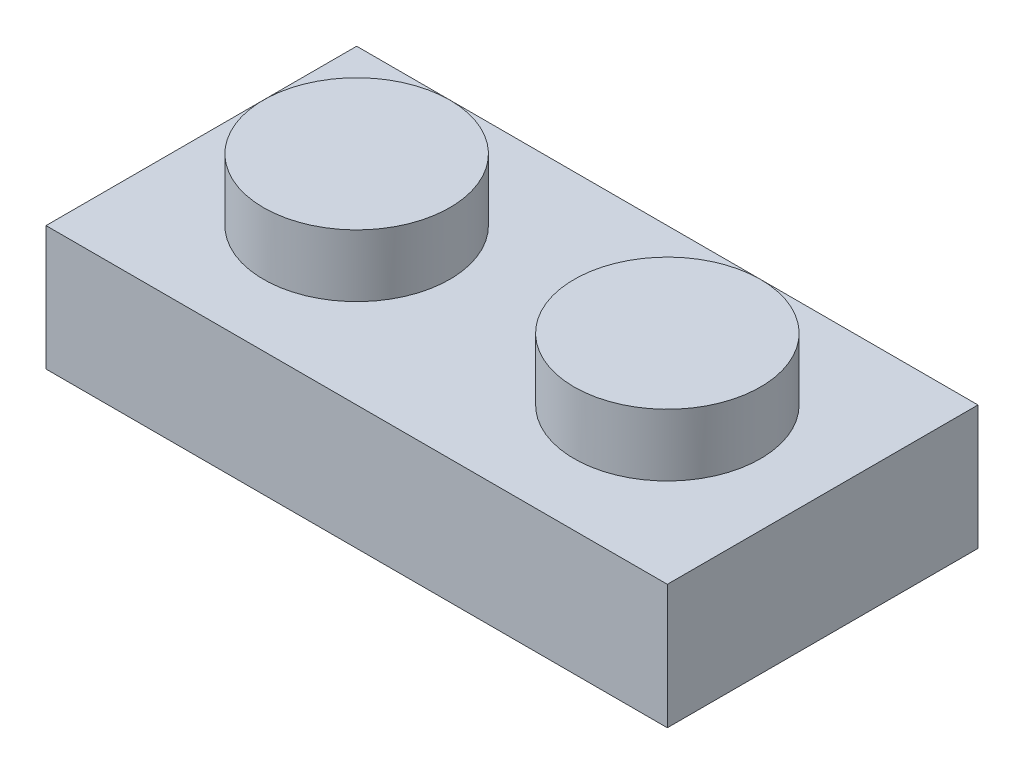
from build123d import *

# Parameters (mm, degrees)
SKETCH1_R             = 1.5
BOSS_EXTRUDE1_DEPTH   = 2
BOSS_EXTRUDE1_2_DEPTH = 2
SKETCH1_3_W           = 10
SKETCH1_3_H           = 5
BOSS_EXTRUDE2_DEPTH   = 1
SKETCH1_4_R           = 0.75
CUT_EXTRUDE1_DEPTH    = 1
SKETCH1_5_W           = 10
SKETCH1_5_H           = 5
SKETCH1_5_W_2         = 8
SKETCH1_5_H_2         = 3
SKETCH1_5_R           = 1
BOSS_EXTRUDE3_DEPTH   = 1


with BuildPart() as part:
    # Sketch1 → Boss-Extrude1 (new body)
    with BuildSketch(Plane(origin=(0, 0, 0), x_dir=(1, 0, 0), z_dir=(0, 1, 0))):
        with Locations((-2.5, 0)):
            Circle(SKETCH1_R)
    extrude(amount=BOSS_EXTRUDE1_DEPTH)



with BuildPart() as body_2:
    # Sketch1 → Boss-Extrude1 2 (new body)
    with BuildSketch(Plane(origin=(0, 0, 0), x_dir=(1, 0, 0), z_dir=(0, 1, 0))):
        with Locations((2.5, 0)):
            Circle(SKETCH1_R)
    extrude(amount=BOSS_EXTRUDE1_2_DEPTH)


with BuildPart() as part_1:
    add(part.part)

    add(body_2.part)  # Boss-Extrude2 merges body 2
    # Sketch1_3 → Boss-Extrude2 (add)
    with BuildSketch(Plane(origin=(0, 0, 0), x_dir=(1, 0, 0), z_dir=(0, 1, 0))):
        Rectangle(SKETCH1_3_W, SKETCH1_3_H)
    extrude(amount=BOSS_EXTRUDE2_DEPTH)

    # Sketch1_4 → Cut-Extrude1 (cut)
    with BuildSketch(Plane(origin=(0, 0, 0), x_dir=(1, 0, 0), z_dir=(0, 1, 0))):
        with Locations((-2.5, 0)):
            Circle(SKETCH1_4_R)
        with Locations((2.5, 0)):
            Circle(SKETCH1_4_R)
    extrude(amount=CUT_EXTRUDE1_DEPTH, mode=Mode.SUBTRACT)

    # Sketch1_5 → Boss-Extrude3 (add)
    # profile 1 of 2: a face of its own
    with BuildSketch(Plane(origin=(0, 0, 0), x_dir=(1, 0, 0), z_dir=(0, 1, 0))):
        Rectangle(SKETCH1_5_W, SKETCH1_5_H)
        Rectangle(SKETCH1_5_W_2, SKETCH1_5_H_2, mode=Mode.SUBTRACT)
    # profile 2 of 2: a face of its own
    with BuildSketch(Plane(origin=(0, 0, 0), x_dir=(1, 0, 0), z_dir=(0, 1, 0))):
        Circle(SKETCH1_5_R)
    extrude(amount=-BOSS_EXTRUDE3_DEPTH)


solid = part_1.part
